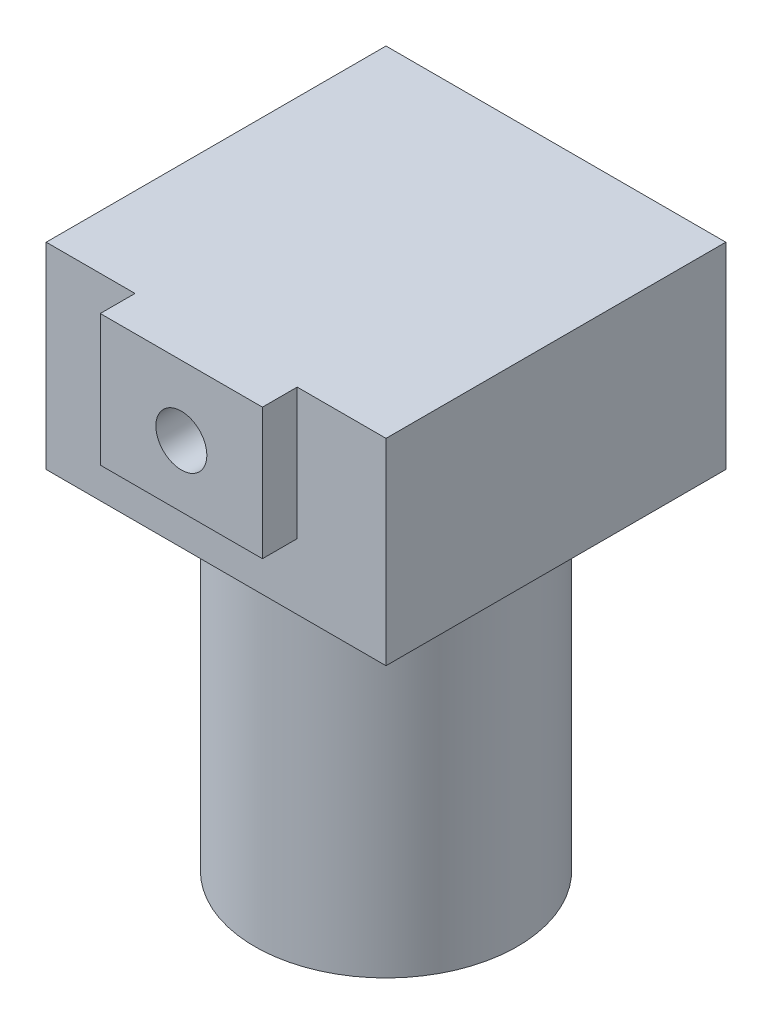
from build123d import *

# Parameters (mm, degrees)
SKETCH1_W           = 44
SKETCH1_H           = 48.5
BOSS_EXTRUDE1_DEPTH = 25.5
CUT_EXTRUDE1_DEPTH  = 4.5
SKETCH3_R           = 3.3
CUT_EXTRUDE2_DEPTH  = 7
SKETCH4_R           = 17
BOSS_EXTRUDE2_DEPTH = 45


with BuildPart() as part:
    # Sketch1 → Boss-Extrude1 (new body)
    with BuildSketch(Plane(origin=(0, 0, 0), x_dir=(1, 0, 0), z_dir=(0, 1, 0))):
        with Locations((22, 24.25)):
            Rectangle(SKETCH1_W, SKETCH1_H)
    extrude(amount=BOSS_EXTRUDE1_DEPTH)

    # Sketch2 → Cut-Extrude1 (cut)
    with BuildSketch(Plane.XY):
        Polygon((11.5, 8.5), (11.5, 25.5), (0, 25.5), (0, 0), (44, 0), (44, 25.5), (32.5, 25.5), (32.5, 8.5), align=None)
    extrude(amount=-CUT_EXTRUDE1_DEPTH, mode=Mode.SUBTRACT)

    # Sketch3 → Cut-Extrude2 (cut)
    with BuildSketch(Plane.XY):
        with Locations((22, 16.5)):
            Circle(SKETCH3_R)
    extrude(amount=-CUT_EXTRUDE2_DEPTH, mode=Mode.SUBTRACT)

    # Sketch4 → Boss-Extrude2 (add)
    with BuildSketch(Plane.XZ):
        with Locations(Location((22, -26.5, 0), (0, 0, 270))):  # turned: the seam where the file's is
            Circle(SKETCH4_R)
    extrude(amount=BOSS_EXTRUDE2_DEPTH)


solid = part.part
